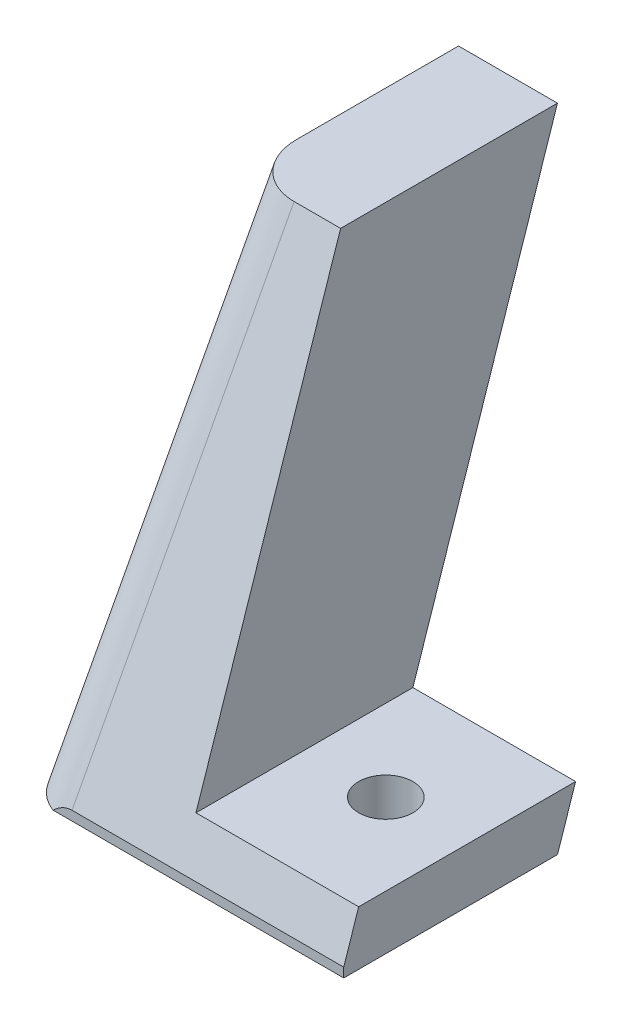
from build123d import *

# Parameters (mm, degrees)
EXTRUDE_1_DEPTH     = 50
CUT_EXTRUDE_1_DEPTH = 50
EXTRUDE_3_DEPTH     = 15
SKETCH_8_R          = 2.5
CUT_EXTRUDE_2_DEPTH = 15
FILLET_1_R          = 5


with BuildPart() as part:
    # Эскиз2 → Бобышка-Вытянуть1 (new body)
    with BuildSketch(Plane.XY):
        Polygon((-39.125, 45), (-45, 0), (-30, 0), (-30, 45), align=None)
    extrude(amount=EXTRUDE_1_DEPTH)

    # Эскиз4 → Вырез-Вытянуть1 (cut)
    with BuildSketch(Plane(origin=(0, 0, 0), x_dir=(0, 0, -1), z_dir=(1, 0, 0))):
        Polygon((-50.288969981, 0), (-50, 45), (-35.288969981, 45), align=None)
        Polygon((-30.288969981, 0), (-15.293288519, 45), (0, 45), (0, 0), align=None)
    extrude(amount=-CUT_EXTRUDE_1_DEPTH, mode=Mode.SUBTRACT)

    # Эскиз7 → Бобышка-Вытянуть3 (add)
    with BuildSketch(Plane(origin=(-30, 0, 0), x_dir=(0, 0, -1), z_dir=(1, 0, 0))):
        Polygon((-50, 0), (-50, 0.866909943), (-48.622303314, 5), (-28.622783152, 5), (-30.288969981, 0), align=None)
    extrude(amount=EXTRUDE_3_DEPTH)

    # Эскиз8 → Вырез-Вытянуть2 (cut)
    with BuildSketch(Plane(origin=(0, 5, 0), x_dir=(1, 0, 0), z_dir=(0, 1, 0))):
        with Locations((-22.5, -38.622543233)):
            Circle(SKETCH_8_R)
    extrude(amount=-CUT_EXTRUDE_2_DEPTH, mode=Mode.SUBTRACT)

    # Скругление1
    fillet_1_edges = [part.edges().sort_by_distance(p)[0] for p in [
        (-42.005910045, 22.933454972, 42.644484991),
    ]]
    fillet(fillet_1_edges, radius=FILLET_1_R)


solid = part.part
